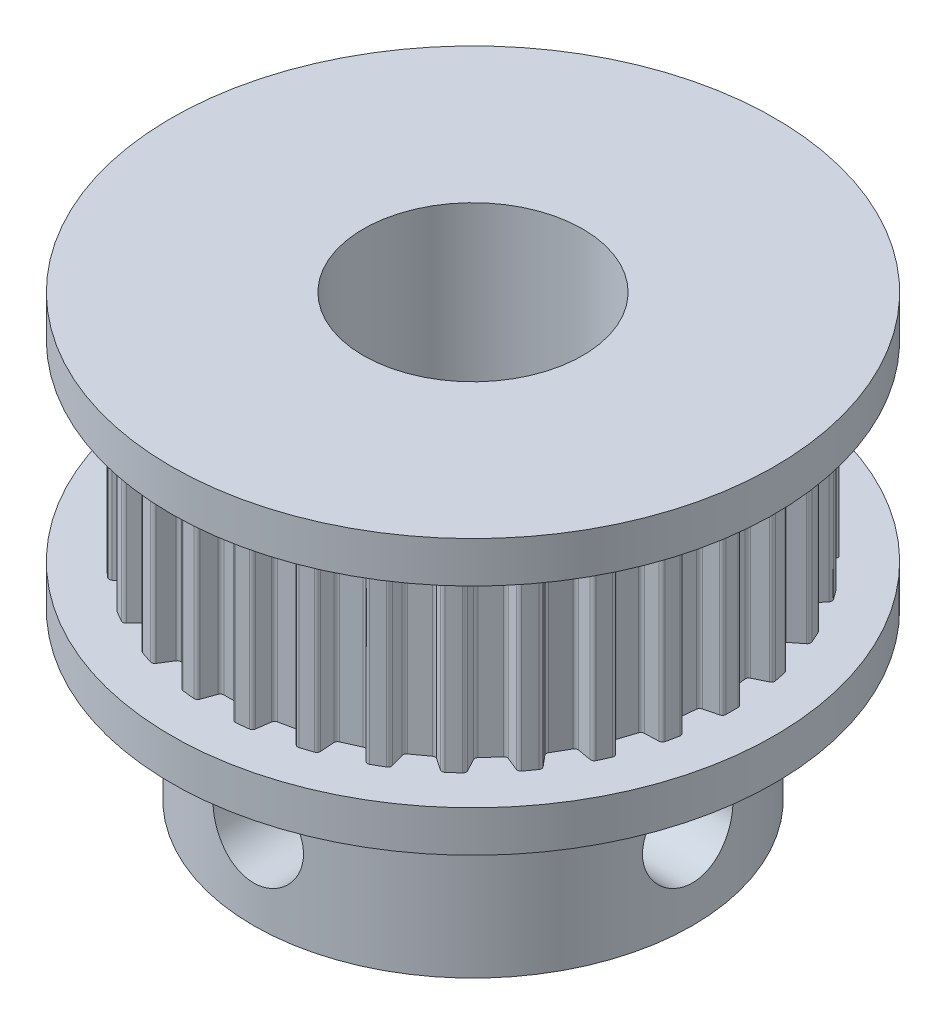
from build123d import *

# Parameters (mm, degrees)
EXTRUDE_1_DEPTH                  = 3.5
EXTRUDE_1_DEPTH_BACK             = 3.5
SKETCH_1_R                       = 9.445
CUT_EXTRUDE_1_DEPTH              = 16.080319957
FILLET_1_R                       = 0.13
PATTERN_CIRCULAR_1_COUNT         = 30
FILLET_1_OF_PATTERN_CIRCULAR_1_R = 0.13
SKETCH_3_R                       = 11
EXTRUDE_2_DEPTH                  = 1.5
EXTRUDE_START                    = 1.5
SKETCH_4_R                       = 11
EXTRUDE_3_DEPTH                  = 1.5
SKETCH_10_R                      = 8
EXTRUDE_4_DEPTH                  = 6
CUT_EXTRUDE_2_DEPTH              = 19.493242009
CUT_EXTRUDE_2_DEPTH_BACK         = 19.493242009
SKETCH_5_R                       = 4
SKETCH_9_W                       = 1.65
SKETCH_9_H                       = 11
PATTERN_CIRCULAR_2_COUNT         = 2
PATTERN_CIRCULAR_2_ANGLE         = 90


with BuildPart() as part:
    # 草圖1 → 填料-伸長1 (new, two sides: drawn at the far end of the back side and taken through both)
    with BuildSketch(Plane(origin=(0, 0, 0), x_dir=(1, 0, 0), z_dir=(0, 1, 0)).offset(-EXTRUDE_1_DEPTH_BACK)):
        Circle(SKETCH_1_R)
    extrude(amount=EXTRUDE_1_DEPTH + EXTRUDE_1_DEPTH_BACK)

    # 草圖2 → 除料-伸長1 (cut, through all)
    with BuildSketch(Plane.XZ.offset(3.5)):
        with BuildLine():
            ThreePointArc((0.662667943, 9.421724693), (0, 9.445), (-0.662667943, 9.421724693))
            Line((-0.662667943, 9.421724693), (-0.42, 8.755))
            Line((-0.42, 8.755), (0.42, 8.755))
            Line((0.42, 8.755), (0.662667943, 9.421724693))
        make_face()
    cut_extrude_1 = extrude(amount=-CUT_EXTRUDE_1_DEPTH, mode=Mode.SUBTRACT)

    # 圓角1
    fillet_1_edges = [part.edges().sort_by_distance(p)[0] for p in [
        (-0.662667943, -1.75, 9.421724693),
        (0.662667943, -1.75, 9.421724693),
        (0.42, 0, 8.755),
        (-0.42, 0, 8.755),
    ]]
    fillet(fillet_1_edges, radius=FILLET_1_R)

    # 環狀複製排列1: 除料-伸長1 ×30 about axis
    pattern_circular_1_axis = Axis((0, -3.5, 0), (0, 1, 0))
    for i in range(1, PATTERN_CIRCULAR_1_COUNT):
        add(cut_extrude_1.rotate(pattern_circular_1_axis, i * 360 / PATTERN_CIRCULAR_1_COUNT), mode=Mode.SUBTRACT)

    # 圓角1 of 環狀複製排列1
    fillet_1_of_pattern_circular_1_edges = [part.edges().sort_by_distance(p)[0] for p in [
        (1.310699653, -1.75, 9.353613816),
        (2.60707377, -1.75, 9.078060991),
        (2.231088845, 0, 8.476359334),
        (1.409444861, 0, 8.651005155),
        (3.226783385, -1.75, 8.876705131),
        (4.437537963, -1.75, 8.337642462),
        (3.944668402, 0, 7.827261092),
        (3.177290218, 0, 8.168919872),
        (5.001841199, -1.75, 8.011841837),
        (6.074060453, -1.75, 7.232828949),
        (5.485847021, 0, 6.83607398),
        (4.806272746, 0, 7.329813592),
        (6.558294551, -1.75, 6.79682261),
        (7.445117355, -1.75, 5.811906104),
        (6.787267802, 0, 5.546117632),
        (6.225198092, 0, 6.170359285),
        (7.82811896, -1.75, 5.284749619),
        (8.490786903, -1.75, 4.136975074),
        (7.79205241, 0, 4.01376933),
        (7.37205241, 0, 4.74123067),
        (8.755817008, -1.75, 3.541707712),
        (9.16536832, -1.75, 2.281238381),
        (8.456286938, 0, 2.306000049),
        (8.196712663, 0, 3.104887523),
        (9.300843838, -1.75, 1.643876182),
        (9.439379161, -1.75, 0.325800625),
        (8.750941149, 0, 0.4974475),
        (8.663137239, 0, 1.332845892),
        (9.439379161, -1.75, -0.325800625),
        (9.300843838, -1.75, -1.643876182),
        (8.663137239, 0, -1.332845892),
        (8.750941149, 0, -0.4974475),
        (9.16536832, -1.75, -2.281238381),
        (8.755817008, -1.75, -3.541707712),
        (8.196712663, 0, -3.104887523),
        (8.456286938, 0, -2.306000049),
        (8.490786903, -1.75, -4.136975074),
        (7.82811896, -1.75, -5.284749619),
        (7.37205241, 0, -4.74123067),
        (7.79205241, 0, -4.01376933),
        (7.445117355, -1.75, -5.811906104),
        (6.558294551, -1.75, -6.79682261),
        (6.225198092, 0, -6.170359285),
        (6.787267802, 0, -5.546117632),
        (6.074060453, -1.75, -7.232828949),
        (5.001841199, -1.75, -8.011841837),
        (4.806272746, 0, -7.329813592),
        (5.485847021, 0, -6.83607398),
        (4.437537963, -1.75, -8.337642462),
        (3.226783385, -1.75, -8.876705131),
        (3.177290218, 0, -8.168919872),
        (3.944668402, 0, -7.827261092),
        (2.60707377, -1.75, -9.078060991),
        (1.310699653, -1.75, -9.353613816),
        (1.409444861, 0, -8.651005155),
        (2.231088845, 0, -8.476359334),
        (0.662667943, -1.75, -9.421724693),
        (-0.662667943, -1.75, -9.421724693),
        (-0.42, 0, -8.755),
        (0.42, 0, -8.755),
        (-1.310699653, -1.75, -9.353613816),
        (-2.60707377, -1.75, -9.078060991),
        (-2.231088845, 0, -8.476359334),
        (-1.409444861, 0, -8.651005155),
        (-3.226783385, -1.75, -8.876705131),
        (-4.437537963, -1.75, -8.337642462),
        (-3.944668402, 0, -7.827261092),
        (-3.177290218, 0, -8.168919872),
        (-5.001841199, -1.75, -8.011841837),
        (-6.074060453, -1.75, -7.232828949),
        (-5.485847021, 0, -6.83607398),
        (-4.806272746, 0, -7.329813592),
        (-6.558294551, -1.75, -6.79682261),
        (-7.445117355, -1.75, -5.811906104),
        (-6.787267802, 0, -5.546117632),
        (-6.225198092, 0, -6.170359285),
        (-7.82811896, -1.75, -5.284749619),
        (-8.490786903, -1.75, -4.136975074),
        (-7.79205241, 0, -4.01376933),
        (-7.37205241, 0, -4.74123067),
        (-8.755817008, -1.75, -3.541707712),
        (-9.16536832, -1.75, -2.281238381),
        (-8.456286938, 0, -2.306000049),
        (-8.196712663, 0, -3.104887523),
        (-9.300843838, -1.75, -1.643876182),
        (-9.439379161, -1.75, -0.325800625),
        (-8.750941149, 0, -0.4974475),
        (-8.663137239, 0, -1.332845892),
        (-9.439379161, -1.75, 0.325800625),
        (-9.300843838, -1.75, 1.643876182),
        (-8.663137239, 0, 1.332845892),
        (-8.750941149, 0, 0.4974475),
        (-9.16536832, -1.75, 2.281238381),
        (-8.755817008, -1.75, 3.541707712),
        (-8.196712663, 0, 3.104887523),
        (-8.456286938, 0, 2.306000049),
        (-8.490786903, -1.75, 4.136975074),
        (-7.82811896, -1.75, 5.284749619),
        (-7.37205241, 0, 4.74123067),
        (-7.79205241, 0, 4.01376933),
        (-7.445117355, -1.75, 5.811906104),
        (-6.558294551, -1.75, 6.79682261),
        (-6.225198092, 0, 6.170359285),
        (-6.787267802, 0, 5.546117632),
        (-6.074060453, -1.75, 7.232828949),
        (-5.001841199, -1.75, 8.011841837),
        (-4.806272746, 0, 7.329813592),
        (-5.485847021, 0, 6.83607398),
        (-4.437537963, -1.75, 8.337642462),
        (-3.226783385, -1.75, 8.876705131),
        (-3.177290218, 0, 8.168919872),
        (-3.944668402, 0, 7.827261092),
        (-2.60707377, -1.75, 9.078060991),
        (-1.310699653, -1.75, 9.353613816),
        (-1.409444861, 0, 8.651005155),
        (-2.231088845, 0, 8.476359334),
    ]]
    fillet(fillet_1_of_pattern_circular_1_edges, radius=FILLET_1_OF_PATTERN_CIRCULAR_1_R)

    # 草圖3 → 填料-伸長2 (add)
    with BuildSketch(Plane(origin=(0, 3.5, 0), x_dir=(1, 0, 0), z_dir=(0, 1, 0))):
        Circle(SKETCH_3_R)
    extrude(amount=EXTRUDE_2_DEPTH)

    # 草圖4 → 填料-伸長3 (add)
    with BuildSketch(Plane.XZ.offset(3.5).offset(EXTRUDE_START)):
        Circle(SKETCH_4_R)
    extrude(amount=-EXTRUDE_3_DEPTH)

    # 草圖10 → 填料-伸長4 (add)
    with BuildSketch(Plane.XZ.offset(5)):
        Circle(SKETCH_10_R)
    extrude(amount=EXTRUDE_4_DEPTH)

    # 草圖5 → 除料-伸長2 (cut, two sides: drawn at the far end of the back side and taken through both)
    with BuildSketch(Plane.XZ.offset(5).offset(-CUT_EXTRUDE_2_DEPTH_BACK)):
        Circle(SKETCH_5_R)
    extrude(amount=CUT_EXTRUDE_2_DEPTH + CUT_EXTRUDE_2_DEPTH_BACK, mode=Mode.SUBTRACT)

    # 草圖9 → M4x0.7 螺紋孔1 (revolve, cut)
    with BuildSketch(Plane(origin=(0, -8, 0), x_dir=(0, 1, 0), z_dir=(1, 0, 0))):
        with Locations((0.825, 5.5)):
            Rectangle(SKETCH_9_W, SKETCH_9_H)
    m4x0_7_1 = revolve(axis=Axis((0, -8, -6.35), (0, 0, 1)), mode=Mode.SUBTRACT)

    # 環狀複製排列2: M4x0.7 螺紋孔1 ×2 about axis
    pattern_circular_2_axis = Axis((0, 5, 0), (0, 1, 0))
    for i in range(1, PATTERN_CIRCULAR_2_COUNT):
        add(m4x0_7_1.rotate(pattern_circular_2_axis, i * PATTERN_CIRCULAR_2_ANGLE / (PATTERN_CIRCULAR_2_COUNT - 1)), mode=Mode.SUBTRACT)


solid = part.part
